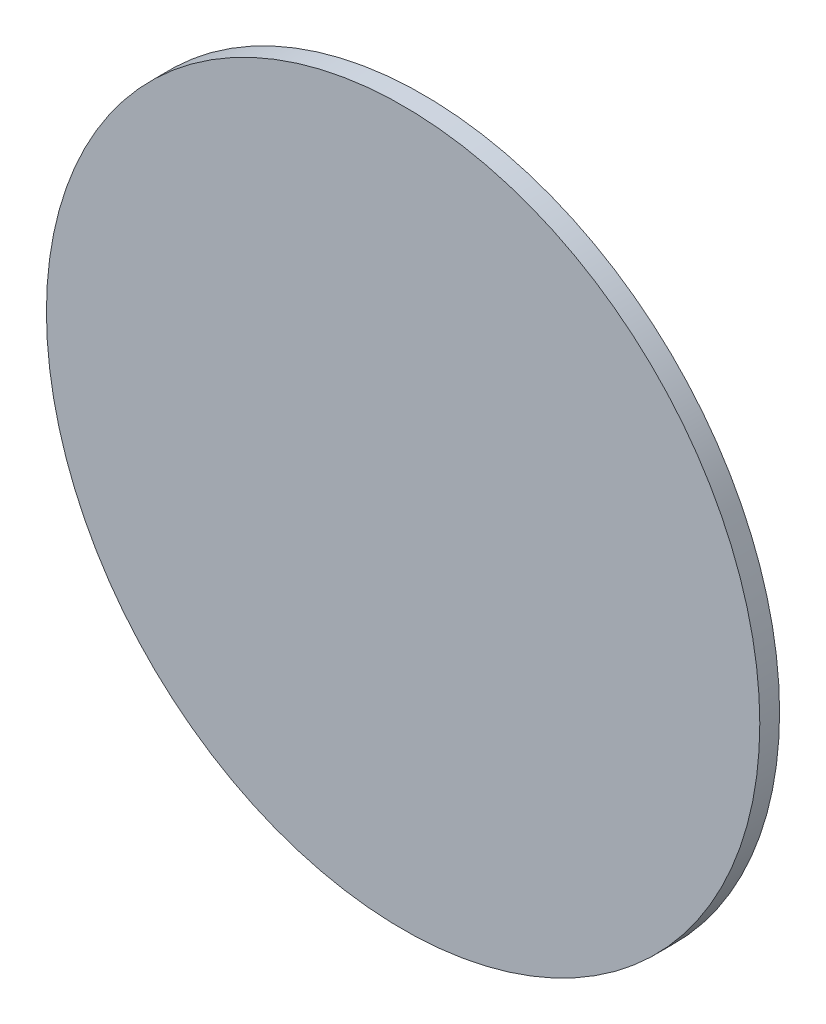
from build123d import *

# Parameters (mm, degrees)
SKETCH1_R           = 133.5
BOSS_EXTRUDE1_DEPTH = 7.4


with BuildPart() as part:
    # Sketch1 → Boss-Extrude1 (new body)
    with BuildSketch(Plane.XY):
        Circle(SKETCH1_R)
    extrude(amount=BOSS_EXTRUDE1_DEPTH)


solid = part.part
